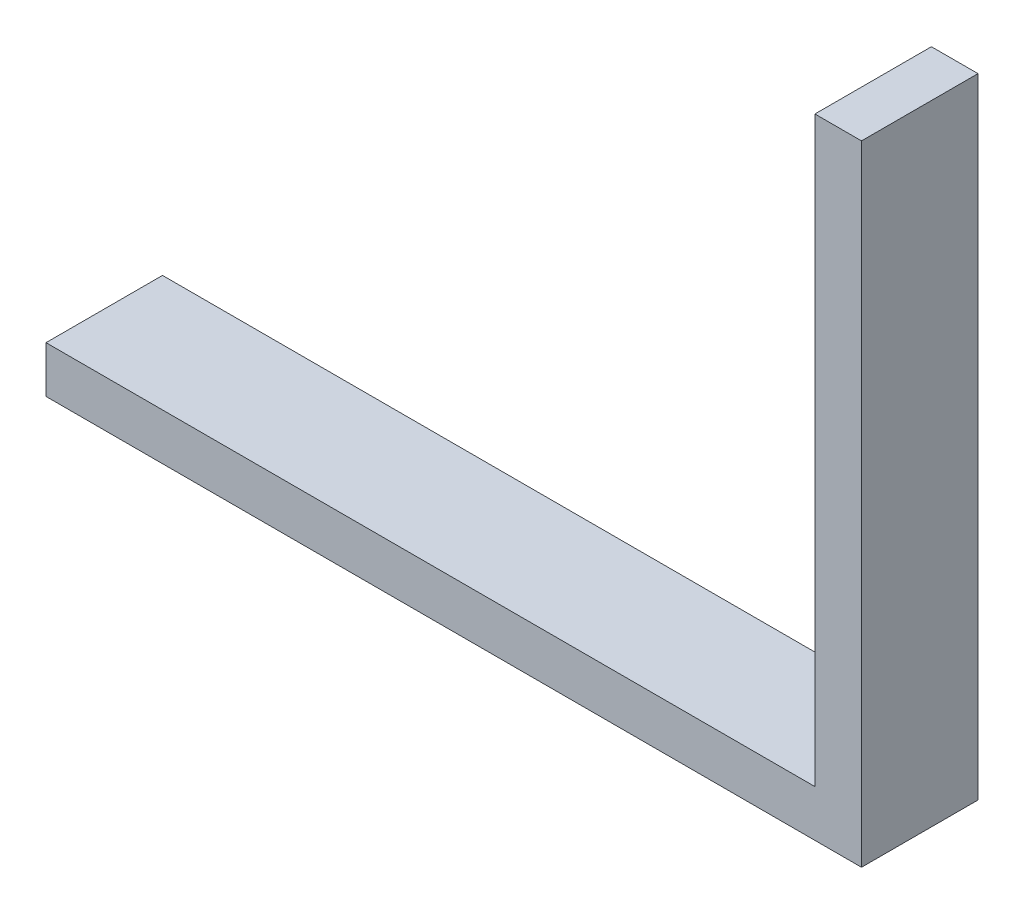
from build123d import *

# Parameters (mm, degrees)
SKETCH1_W           = 35
SKETCH1_H           = 5
BOSS_EXTRUDE3_DEPTH = 2
SKETCH3_W           = 2
SKETCH3_H           = 5
BOSS_EXTRUDE4_DEPTH = 25


with BuildPart() as part:
    # Sketch1 → Boss-Extrude3 (new body)
    with BuildSketch(Plane(origin=(0, 0, 0), x_dir=(1, 0, 0), z_dir=(0, 1, 0))):
        Rectangle(SKETCH1_W, SKETCH1_H)
    extrude(amount=BOSS_EXTRUDE3_DEPTH)

    # Sketch3 → Boss-Extrude4 (add)
    with BuildSketch(Plane(origin=(0, 2, 0), x_dir=(1, 0, 0), z_dir=(0, 1, 0))):
        with Locations((16.5, 0)):
            Rectangle(SKETCH3_W, SKETCH3_H)
    extrude(amount=BOSS_EXTRUDE4_DEPTH)


solid = part.part
